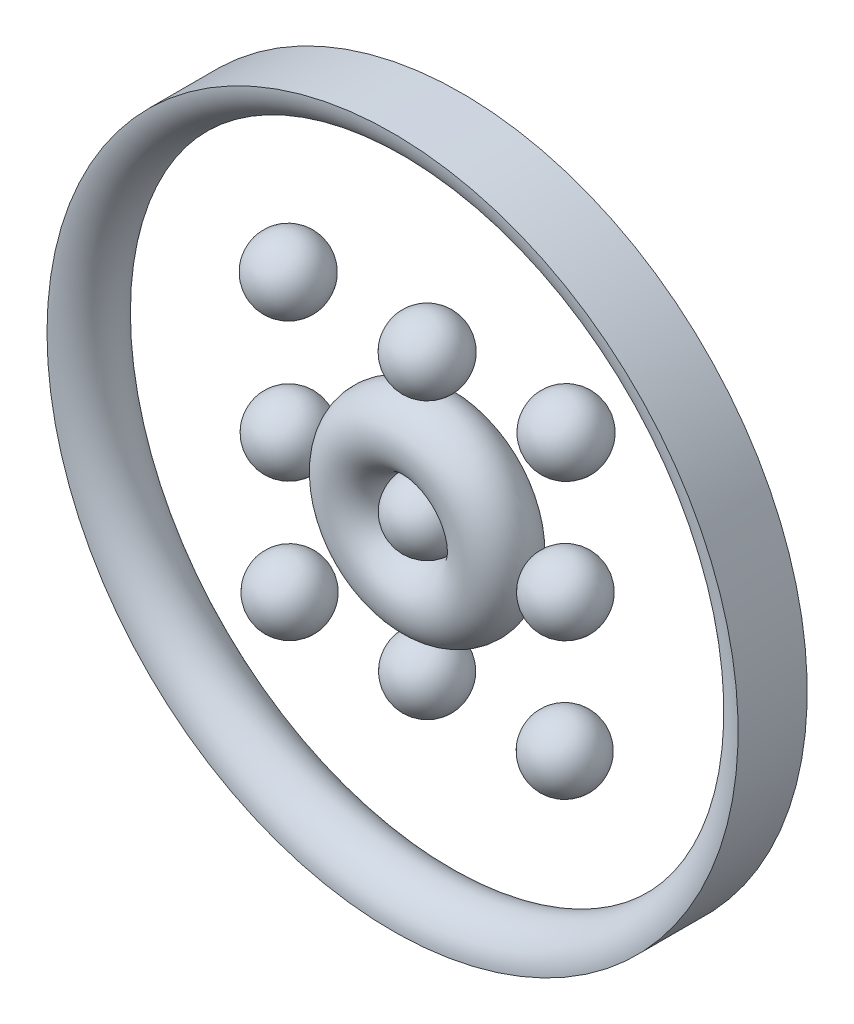
from build123d import *

# Parameters (mm, degrees)
SKETCH25_R = 30.233391066


with BuildPart() as part:
    # Sketch16 → Revolve12 (revolve)
    with BuildSketch(Plane.XY):
        with BuildLine():
            Line((30.307686127, 24696.930669747), (-30.307686127, 24696.930669747))
            ThreePointArc((-30.307686127, 24696.930669747), (0, 24727.238355873), (30.307686127, 24696.930669747))
        make_face()
    revolve(axis=Axis((30.307686127, 24696.930669747, 0), (-1, 0, 0)))


with BuildPart() as body_2:
    # Sketch17 → Revolve13 (revolve)
    with BuildSketch(Plane.XY):
        with BuildLine():
            Line((30.159278129, 24575.996923359), (-30.159278129, 24575.996923359))
            ThreePointArc((-30.159278129, 24575.996923359), (0, 24606.156201488), (30.159278129, 24575.996923359))
        make_face()
    revolve(axis=Axis((30.159278129, 24575.996923359, 0), (-1, 0, 0)))


with BuildPart() as body_3:
    # Sketch18 → Revolve14 (revolve)
    with BuildSketch(Plane.XY):
        with BuildLine():
            Line((30.456824411, 24818.459507802), (-30.456824411, 24818.459507802))
            ThreePointArc((-30.456824411, 24818.459507802), (0, 24848.916332214), (30.456824411, 24818.459507802))
        make_face()
    revolve(axis=Axis((30.456824411, 24818.459507802, 0), (-1, 0, 0)))


with BuildPart() as body_4:
    # Sketch19 → Revolve15 (revolve)
    with BuildSketch(Plane.XY):
        with BuildLine():
            Line((150.795936452, 24575.700835859), (90.477380194, 24575.700835859))
            ThreePointArc((90.477380194, 24575.700835859), (120.636658323, 24605.860113988), (150.795936452, 24575.700835859))
        make_face()
    revolve(axis=Axis((150.795936452, 24575.700835859, 0), (-1, 0, 0)))


with BuildPart() as body_5:
    # Sketch20 → Revolve16 (revolve)
    with BuildSketch(Plane.XY):
        with BuildLine():
            Line((-90.477380194, 24575.700835859), (-150.795936452, 24575.700835859))
            ThreePointArc((-150.795936452, 24575.700835859), (-120.636658323, 24605.860113988), (-90.477380194, 24575.700835859))
        make_face()
    revolve(axis=Axis((-90.477380194, 24575.700835859, 0), (-1, 0, 0)))


with BuildPart() as body_6:
    # Sketch21 → Revolve17 (revolve)
    with BuildSketch(Plane.XY):
        with BuildLine():
            Line((151.537974205, 24696.633125257), (90.922601952, 24696.633125257))
            ThreePointArc((90.922601952, 24696.633125257), (121.230288078, 24726.940811383), (151.537974205, 24696.633125257))
        make_face()
    revolve(axis=Axis((151.537974205, 24696.633125257, 0), (-1, 0, 0)))


with BuildPart() as body_7:
    # Sketch22 → Revolve18 (revolve)
    with BuildSketch(Plane.XY):
        with BuildLine():
            Line((-90.922601952, 24696.633125257), (-151.537974205, 24696.633125257))
            ThreePointArc((-151.537974205, 24696.633125257), (-121.230288078, 24726.940811383), (-90.922601952, 24696.633125257))
        make_face()
    revolve(axis=Axis((-90.922601952, 24696.633125257, 0), (-1, 0, 0)))


with BuildPart() as body_8:
    # Sketch23 → Revolve19 (revolve)
    with BuildSketch(Plane.XY):
        with BuildLine():
            Line((152.283663383, 24818.160499153), (91.37001456, 24818.160499153))
            ThreePointArc((91.37001456, 24818.160499153), (121.826838972, 24848.617323565), (152.283663383, 24818.160499153))
        make_face()
    revolve(axis=Axis((152.283663383, 24818.160499153, 0), (-1, 0, 0)))


with BuildPart() as body_9:
    # Sketch24 → Revolve20 (revolve)
    with BuildSketch(Plane.XY):
        with BuildLine():
            Line((-91.37001456, 24818.160499153), (-152.283663383, 24818.160499153))
            ThreePointArc((-152.283663383, 24818.160499153), (-121.826838971, 24848.617323565), (-91.37001456, 24818.160499153))
        make_face()
    revolve(axis=Axis((-91.37001456, 24818.160499153, 0), (-1, 0, 0)))


with BuildPart() as body_10:
    # Sketch25 → Revolve21 (revolve)
    with BuildSketch(Plane(origin=(0, 0, 0), x_dir=(0, 0, -1), z_dir=(1, 0, 0)), mode=Mode.PRIVATE) as revolve21_sk:
        with Locations((0, 24636.389592554)):
            Circle(SKETCH25_R)
    revolve(revolve21_sk.sketch.rotate(Axis((0, 24696.930669747, 0), (0, 0, 1)), 180), axis=Axis((0, 24696.930669747, 0), (0, 0, 1)))  # turned: the seam where the file's is


with BuildPart() as body_11:
    # Sketch26 → Revolve22 (revolve)
    with BuildSketch(Plane(origin=(0, 0, 0), x_dir=(0, 0, -1), z_dir=(1, 0, 0)), mode=Mode.PRIVATE) as revolve22_sk:
        with BuildLine():
            Line((30.305632222, 25000), (-30.305632222, 25000))
            ThreePointArc((-30.305632222, 25000), (0, 24969.694367778), (30.305632222, 25000))
        make_face()
    revolve(revolve22_sk.sketch.rotate(Axis((0, 24696.930669747, 0), (0, 0, 1)), 90), axis=Axis((0, 24696.930669747, 0), (0, 0, 1)))  # turned: the seam where the file's is


solid = Compound([part.part, body_2.part, body_3.part, body_4.part, body_5.part, body_6.part, body_7.part, body_8.part, body_9.part, body_10.part, body_11.part])
